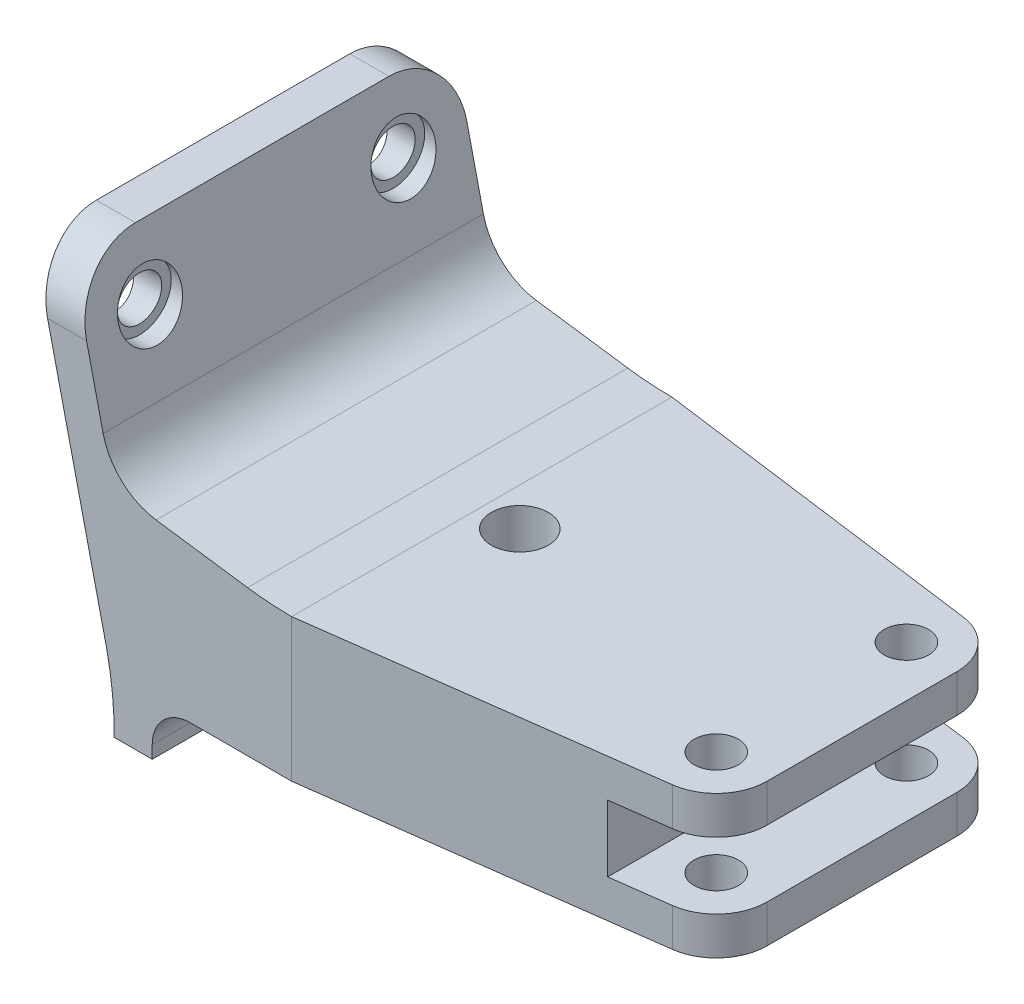
from build123d import *

# Parameters (mm, degrees)
BOSS_EXTRUDE1_DEPTH = 15
SKETCH2_R           = 1.75
SKETCH2_R_2         = 2.25
CUT_EXTRUDE1_DEPTH  = 16.25
SKETCH6_R           = 1.75
CUT_EXTRUDE4_DEPTH  = 51.639881715
SKETCH8_R           = 2.5
CUT_EXTRUDE5_DEPTH  = 2


with BuildPart() as part:
    # Sketch1 → Boss-Extrude1 (new body, symmetric)
    with BuildSketch(Plane.XY):
        with BuildLine():
            Line((25.416367975, 5.477977632), (19.360118285, 31.75))
            Line((19.360118285, 31.75), (22.438796391, 31.75))
            Line((22.438796391, 31.75), (25.127779039, 20.085188295))
            ThreePointArc((25.127779039, 20.085188295), (26.621571391, 17.522387939), (29.304484295, 16.256947461))
            Line((29.304484295, 16.256947461), (36.522421475, 15.243052539))
            ThreePointArc((36.522421475, 15.243052539), (38.256969096, 15.060837158), (40, 15))
            Line((40, 15), (70, 15))
            Line((70, 15), (70, 12))
            Line((70, 12), (62, 12))
            Line((62, 12), (62, 6.75))
            Line((62, 6.75), (70, 6.75))
            Line((70, 6.75), (70, 3.75))
            Line((70, 3.75), (32, 3.75))
            ThreePointArc((32, 3.75), (29.878679656, 2.871320344), (29, 0.75))
            Line((29, 0.75), (29, -0.25))
            Line((29, -0.25), (25.998798049, -0.25))
            ThreePointArc((25.998798049, -0.25), (25.866624369, 2.6301604), (25.416367975, 5.477977632))
        make_face()
    extrude(amount=BOSS_EXTRUDE1_DEPTH, both=True)

    # Sketch2 → Cut-Extrude1 (cut, through all)
    with BuildSketch(Plane(origin=(0, 15, 0), x_dir=(1, 0, 0), z_dir=(0, 1, 0))):
        with Locations((66, 7.5)):
            Circle(SKETCH2_R)
        with Locations((43, 0)):
            Circle(SKETCH2_R_2)
        with Locations((66, -7.5)):
            Circle(SKETCH2_R)
        with BuildLine():
            Line((70, 7.5), (70, 15))
            Line((70, 15), (40, 15))
            Line((40, 15), (66.528351549, 11.464952035))
            ThreePointArc((66.528351549, 11.464952035), (69.009435678, 10.135013644), (70, 7.5))
        make_face()
        with BuildLine():
            Line((40, -15), (66.528351549, -11.464952035))
            ThreePointArc((66.528351549, -11.464952035), (69.009435678, -10.135013644), (70, -7.5))
            Line((70, -7.5), (70, -15))
            Line((70, -15), (40, -15))
        make_face()
    extrude(amount=-CUT_EXTRUDE1_DEPTH, mode=Mode.SUBTRACT)

    # Sketch6 → Cut-Extrude4 (cut, through all)
    with BuildSketch(Plane(origin=(70, 0, 0), x_dir=(0, 0, -1), z_dir=(1, 0, 0))):
        with Locations((-10, 25.75)):
            Circle(SKETCH6_R)
        with Locations((10, 25.75)):
            Circle(SKETCH6_R)
        with BuildLine():
            Line((-10, 30.75), (10, 30.75))
            ThreePointArc((10, 30.75), (13.535533906, 29.285533906), (15, 25.75))
            Line((15, 25.75), (15, 31.75))
            Line((15, 31.75), (-15, 31.75))
            Line((-15, 31.75), (-15, 25.75))
            ThreePointArc((-15, 25.75), (-13.535533906, 29.285533906), (-10, 30.75))
        make_face()
    extrude(amount=-CUT_EXTRUDE4_DEPTH, mode=Mode.SUBTRACT)

    # Sketch8 → Cut-Extrude5 (cut)
    with BuildSketch(Plane(origin=(25, 0, 0), x_dir=(0, 0, -1), z_dir=(1, 0, 0))):
        with Locations((-10, 25.75)):
            Circle(SKETCH8_R)
        with Locations((10, 25.75)):
            Circle(SKETCH8_R)
    extrude(amount=-CUT_EXTRUDE5_DEPTH, mode=Mode.SUBTRACT)


solid = part.part
